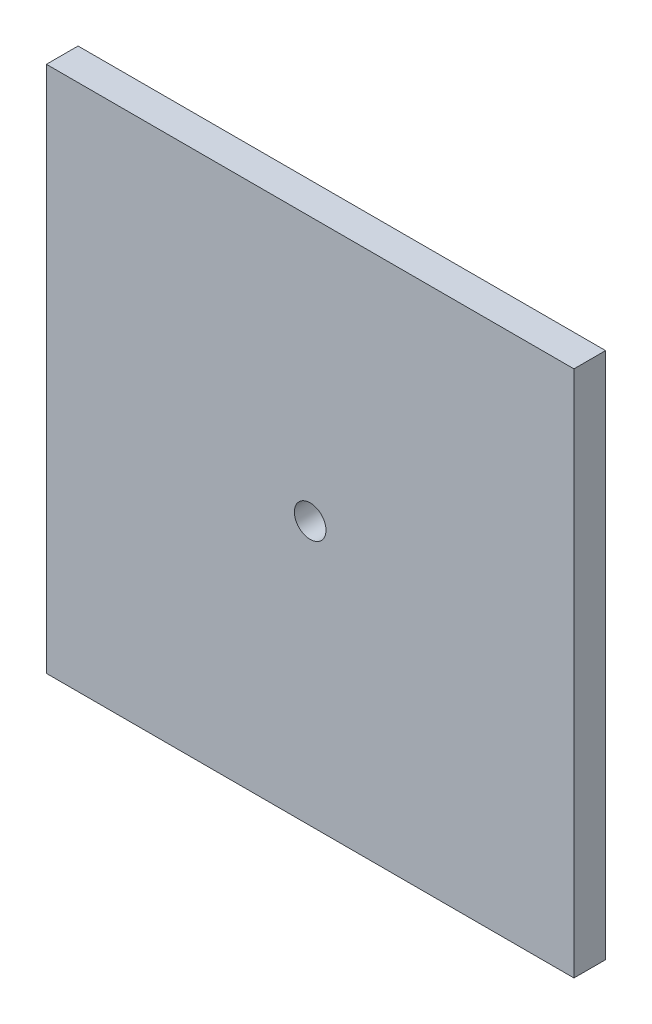
from build123d import *

# Parameters (mm, degrees)
SKETCH1_W               = 50
SKETCH1_H               = 50
BOSS_EXTRUDE1_DEPTH     = 3
SKETCH2_R               = 1.5
CUT_EXTRUDE1_DEPTH      = 1
CUT_EXTRUDE1_DEPTH_BACK = 4


with BuildPart() as part:
    # Sketch1 → Boss-Extrude1 (new body)
    with BuildSketch(Plane.XY):
        Rectangle(SKETCH1_W, SKETCH1_H)
    extrude(amount=BOSS_EXTRUDE1_DEPTH)

    # Sketch2 → Cut-Extrude1 (cut, two sides)
    with BuildSketch(Plane.XY.offset(3)) as cut_extrude1_sk:
        Circle(SKETCH2_R)
    extrude(amount=CUT_EXTRUDE1_DEPTH, mode=Mode.SUBTRACT)
    extrude(cut_extrude1_sk.sketch, amount=-CUT_EXTRUDE1_DEPTH_BACK, mode=Mode.SUBTRACT)


solid = part.part
